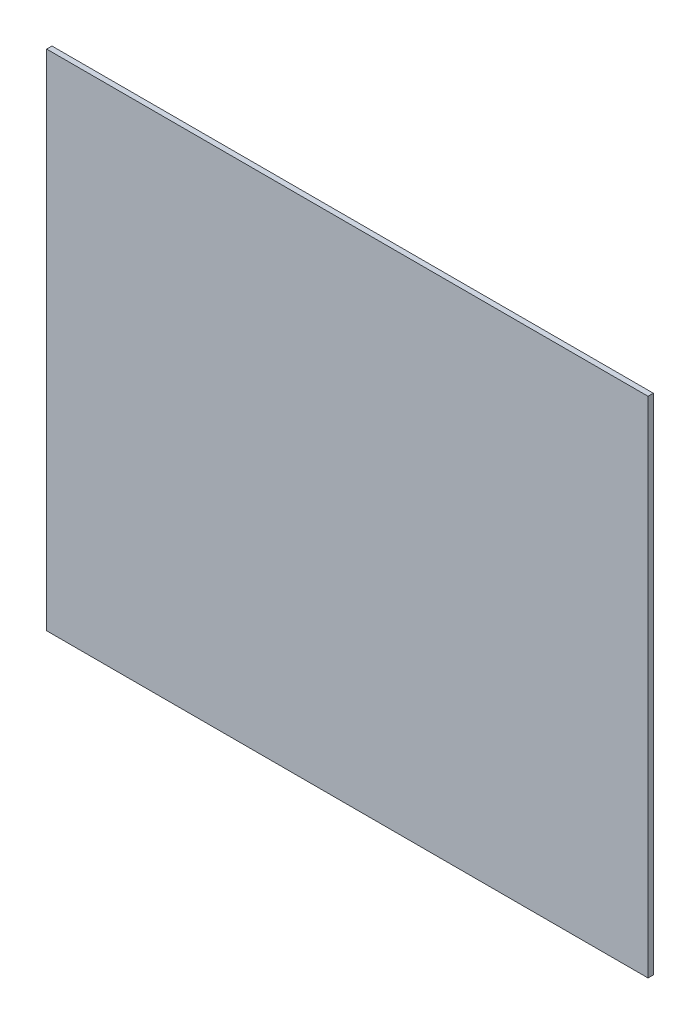
from build123d import *

# Parameters (mm, degrees)
SKETCH_1_W      = 339
SKETCH_1_H      = 284
EXTRUDE_1_DEPTH = 3


with BuildPart() as part:
    # 草图1 → 凸台-拉伸1 (new body)
    with BuildSketch(Plane.XY):
        with Locations((84.403640613, -85.800857139)):
            Rectangle(SKETCH_1_W, SKETCH_1_H)
    extrude(amount=EXTRUDE_1_DEPTH)


solid = part.part
